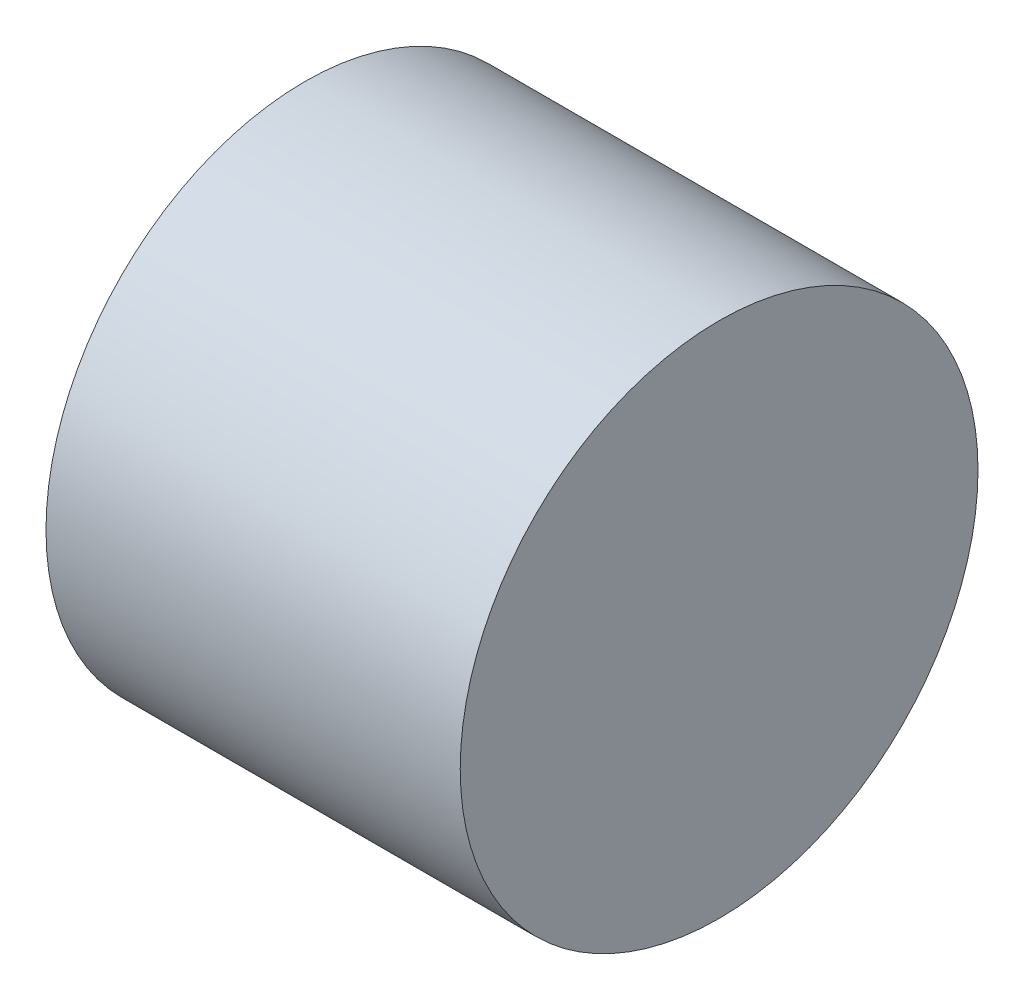
from build123d import *

# Parameters (mm, degrees)
SKETCH1_R           = 25
BOSS_EXTRUDE1_DEPTH = 40


with BuildPart() as part:
    # Sketch1 → Boss-Extrude1 (new body)
    with BuildSketch(Plane(origin=(0, 0, 0), x_dir=(0, 0, -1), z_dir=(1, 0, 0))):
        Circle(SKETCH1_R)
    extrude(amount=BOSS_EXTRUDE1_DEPTH)


solid = part.part
